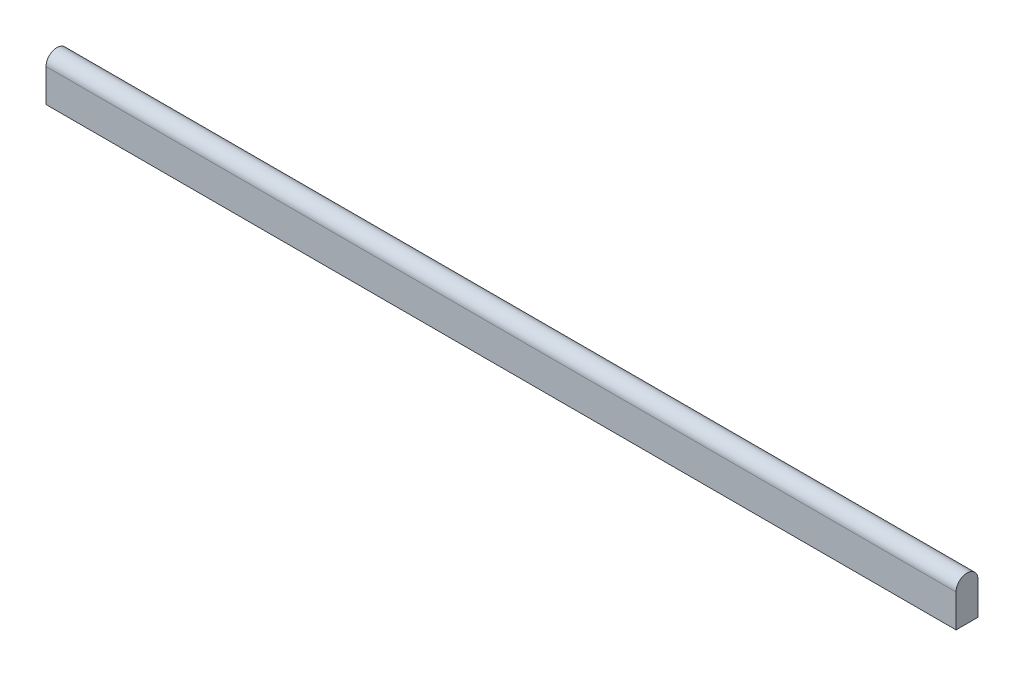
from build123d import *

# Parameters (mm, degrees)
EXTRUSION1_DEPTH = 166


with BuildPart() as part:
    # Esquisse1 → Extrusion1 (new body)
    with BuildSketch(Plane(origin=(0, 0, 0), x_dir=(0, 0, -1), z_dir=(1, 0, 0))):
        with BuildLine():
            Line((-2, 0), (-2, -6))
            Line((-2, -6), (2, -6))
            Line((2, -6), (2, 0))
            ThreePointArc((2, 0), (0, 2), (-2, 0))
        make_face()
    extrude(amount=EXTRUSION1_DEPTH)


solid = part.part
